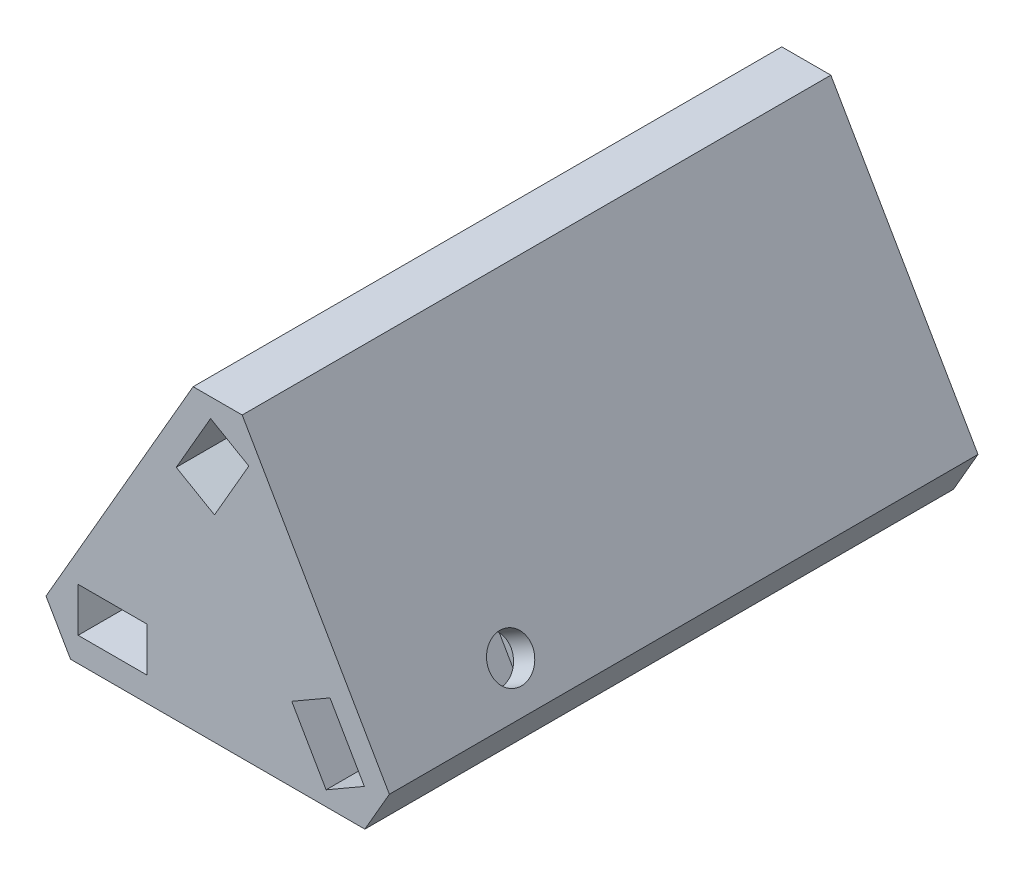
from build123d import *

# Parameters (mm, degrees)
BOSS_EXTRUDE1_DEPTH  = 60
CHAMFER1_SIZE        = 5
CHAMFER1_EDGE_2_SIZE = 5
CHAMFER1_EDGE_3_SIZE = 5
SKETCH2_W            = 7
SKETCH2_H            = 4.5
CUT_EXTRUDE1_DEPTH   = 19.5
SKETCH3_R            = 2.2
CUT_EXTRUDE2_DEPTH   = 2.5
CIRPATTERN1_COUNT    = 3


with BuildPart() as part:
    # Sketch1 → Boss-Extrude1 (new body)
    with BuildSketch(Plane.XY):
        Polygon((-20, -11.547005384), (20, -11.547005384), (0, 23.094010768), align=None)
    extrude(amount=BOSS_EXTRUDE1_DEPTH)

    # Chamfer1
    chamfer1_edges = [part.edges().sort_by_distance(p)[0] for p in [
        (0, 23.094010768, 30),
    ]]
    chamfer(chamfer1_edges, length=CHAMFER1_SIZE)

    # Chamfer1 edge 2
    chamfer1_edge_2_edges = [part.edges().sort_by_distance(p)[0] for p in [
        (20, -11.547005384, 30),
    ]]
    chamfer(chamfer1_edge_2_edges, length=CHAMFER1_EDGE_2_SIZE)

    # Chamfer1 edge 3
    chamfer1_edge_3_edges = [part.edges().sort_by_distance(p)[0] for p in [
        (-20, -11.547005384, 30),
    ]]
    chamfer(chamfer1_edge_3_edges, length=CHAMFER1_EDGE_3_SIZE)

    # Sketch2 → Cut-Extrude1 (cut)
    with BuildSketch(Plane.XY.offset(60)):
        with Locations((-10.726497308, -6.797005384)):
            Rectangle(SKETCH2_W, SKETCH2_H)
    cut_extrude1 = extrude(amount=-CUT_EXTRUDE1_DEPTH, mode=Mode.SUBTRACT)

    # Sketch3 → Cut-Extrude2 (cut)
    with BuildSketch(Plane.XZ.offset(11.547005384)):
        with Locations((-10.726497308, 45.5)):
            Circle(SKETCH3_R)
    cut_extrude2 = extrude(amount=-CUT_EXTRUDE2_DEPTH, mode=Mode.SUBTRACT)

    # CirPattern1: Cut-Extrude1, Cut-Extrude2 ×3 about axis
    cirpattern1_axis = Axis((0, 0, 0), (0, 0, 1))
    for i in range(1, CIRPATTERN1_COUNT):
        add(cut_extrude1.rotate(cirpattern1_axis, i * 360 / CIRPATTERN1_COUNT), mode=Mode.SUBTRACT)
        add(cut_extrude2.rotate(cirpattern1_axis, i * 360 / CIRPATTERN1_COUNT), mode=Mode.SUBTRACT)


solid = part.part
